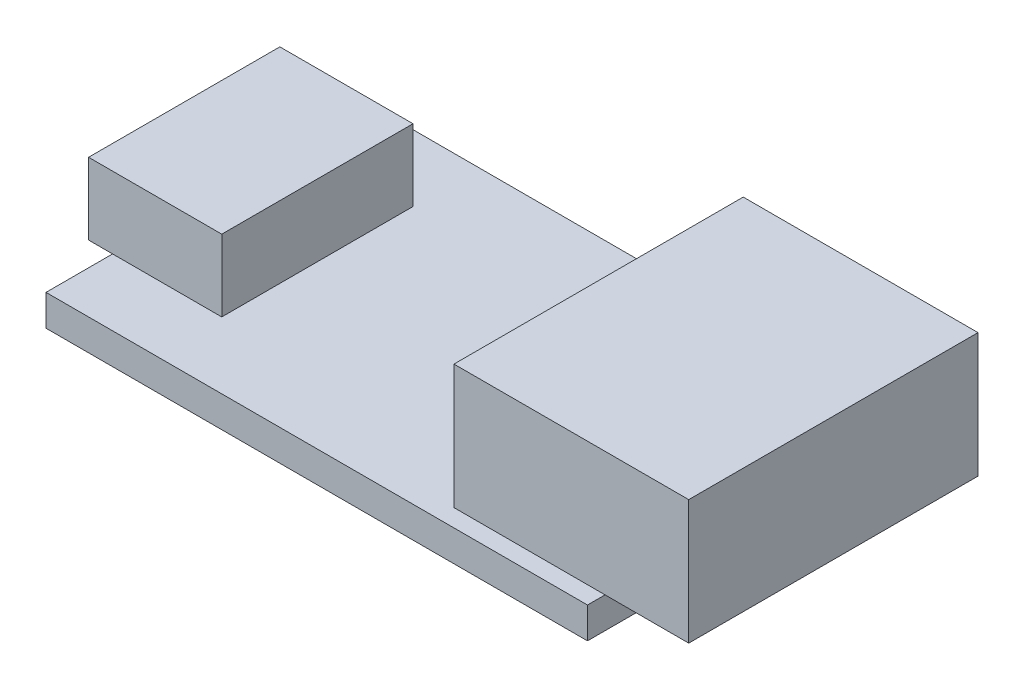
from build123d import *

# Parameters (mm, degrees)
SKETCH1_W           = 22.65
SKETCH1_H           = 13.57
BOSS_EXTRUDE1_DEPTH = 1.3
SKETCH1_3_W         = 9.82
SKETCH1_3_H         = 12.1
BOSS_EXTRUDE2_DEPTH = 5.2
SKETCH1_4_W         = 5.57
SKETCH1_4_H         = 8
BOSS_EXTRUDE3_DEPTH = 3


with BuildPart() as part:
    # Sketch1 → Boss-Extrude1 (new body)
    with BuildSketch(Plane(origin=(0, 0, 0), x_dir=(1, 0, 0), z_dir=(0, 1, 0))):
        with Locations((11.325, 0)):
            Rectangle(SKETCH1_W, SKETCH1_H)
    extrude(amount=-BOSS_EXTRUDE1_DEPTH)


with BuildPart() as body_2:
    # Sketch1_3 → Boss-Extrude2 (new body)
    with BuildSketch(Plane(origin=(0, 0, 0), x_dir=(1, 0, 0), z_dir=(0, 1, 0))):
        with Locations((21.24, 0)):
            Rectangle(SKETCH1_3_W, SKETCH1_3_H)
    extrude(amount=BOSS_EXTRUDE2_DEPTH)


with BuildPart() as body_3:
    # Sketch1_4 → Boss-Extrude3 (new body)
    with BuildSketch(Plane(origin=(0, 0, 0), x_dir=(1, 0, 0), z_dir=(0, 1, 0))):
        with Locations((1.78159017, 0)):
            Rectangle(SKETCH1_4_W, SKETCH1_4_H)
    extrude(amount=BOSS_EXTRUDE3_DEPTH)


solid = Compound([part.part, body_2.part, body_3.part])
